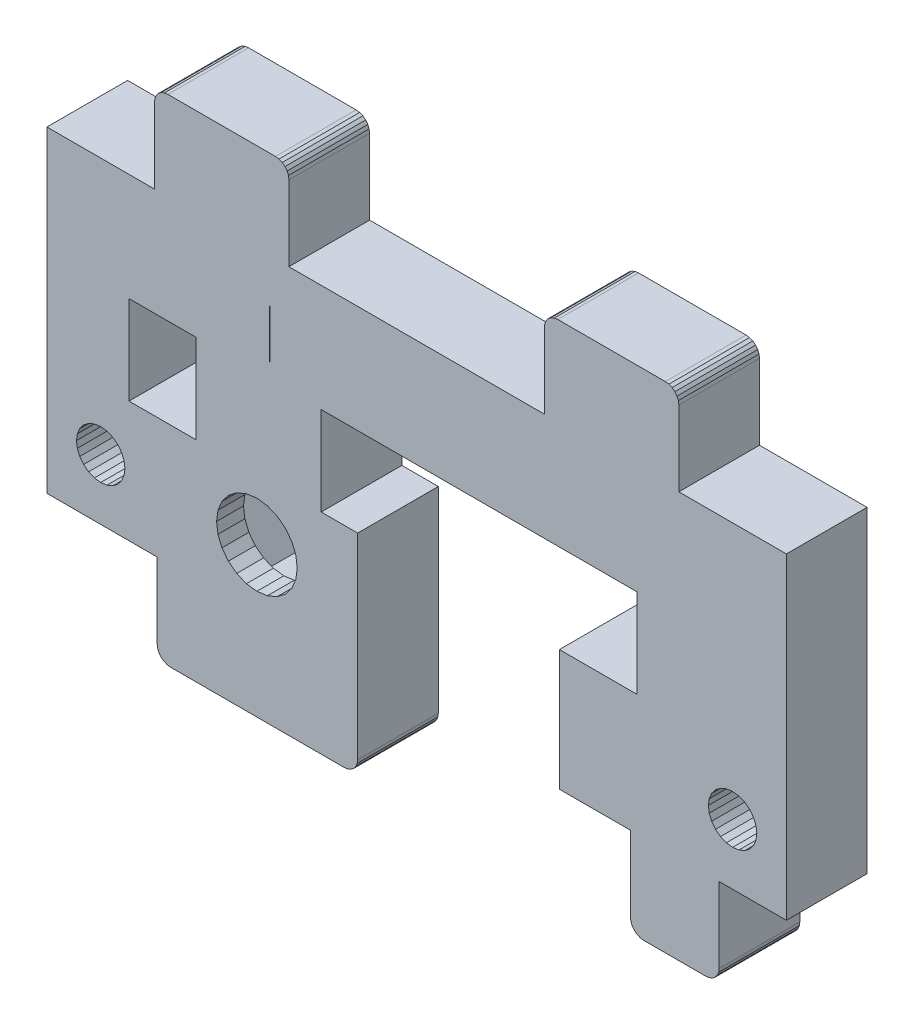
from build123d import *

# Parameters (mm, degrees)
BOSS_EXTRUDE1_DEPTH = 6
BOSS_EXTRUDE2_DEPTH = 2


with BuildPart() as part:
    # Sketch1 → Boss-Extrude1 (new body)
    with BuildSketch(Plane.XY):
        Polygon((-427.733097117, -199.387732928), (-427.525990336, -199.228814306), (-427.367071713, -199.021707525), (-427.267171291, -198.78052657), (-427.233097117, -198.521707525), (-427.233097117, -183.921707525), (-429.945372541, -183.921707525), (-429.945372541, -177.321707525), (-406.445372541, -177.321707525), (-406.445372541, -183.921707525), (-412.227908952, -183.921707525), (-412.227908952, -192.921707525), (-406.945372541, -192.921707525), (-406.945372541, -198.521707525), (-406.911298367, -198.78052657), (-406.811397945, -199.021707525), (-406.652479322, -199.228814306), (-406.445372541, -199.387732928), (-406.204191586, -199.487633351), (-405.945372541, -199.521707525), (-401.345372541, -199.521707525), (-401.086553496, -199.487633351), (-400.845372541, -199.387732928), (-400.63826576, -199.228814306), (-400.479347137, -199.021707525), (-400.379446715, -198.78052657), (-400.345372541, -198.521707525), (-400.345372541, -192.921707525), (-395.345372541, -192.921707525), (-395.345372541, -169.321707525), (-403.345372541, -169.321707525), (-403.345372541, -163.721707525), (-403.379446715, -163.46288848), (-403.479347137, -163.221707525), (-403.63826576, -163.014600744), (-403.845372541, -162.855682121), (-404.086553496, -162.755781698), (-404.345372541, -162.721707525), (-412.345372541, -162.721707525), (-412.604191586, -162.755781698), (-412.845372541, -162.855682121), (-413.052479322, -163.014600744), (-413.211397945, -163.221707525), (-413.311298367, -163.46288848), (-413.345372541, -163.721707525), (-413.345372541, -169.321707525), (-432.345372541, -169.321707525), (-432.345372541, -163.721707525), (-432.379446715, -163.46288848), (-432.479347137, -163.221707525), (-432.63826576, -163.014600744), (-432.845372541, -162.855682121), (-433.086553496, -162.755781698), (-433.345372541, -162.721707525), (-441.345372541, -162.721707525), (-441.604191586, -162.755781698), (-441.845372541, -162.855682121), (-442.052479322, -163.014600744), (-442.211397945, -163.221707525), (-442.311298367, -163.46288848), (-442.345372541, -163.721707525), (-442.345372541, -169.321707525), (-450.345372541, -169.321707525), (-450.345372541, -192.921707525), (-442.145372541, -192.921707525), (-442.145372541, -198.521707525), (-442.111298367, -198.78052657), (-442.011397945, -199.021707525), (-441.852479322, -199.228814306), (-441.645372541, -199.387732928), (-441.404191586, -199.487633351), (-441.145372541, -199.521707525), (-428.233097117, -199.521707525), (-427.974278072, -199.487633351), align=None)
        Polygon((-447.618164747, -187.148915319), (-447.245372541, -186.862861798), (-446.811246822, -186.683041037), (-446.345372541, -186.621707525), (-445.87949826, -186.683041037), (-445.445372541, -186.862861798), (-445.072580335, -187.148915319), (-444.786526814, -187.521707525), (-444.606706054, -187.955833244), (-444.545372541, -188.421707525), (-444.606706054, -188.887581806), (-444.786526814, -189.321707525), (-445.072580335, -189.694499731), (-445.445372541, -189.980553252), (-445.87949826, -190.160374012), (-446.345372541, -190.221707525), (-446.811246822, -190.160374012), (-447.245372541, -189.980553252), (-447.618164747, -189.694499731), (-447.904218268, -189.321707525), (-448.084039028, -188.887581806), (-448.145372541, -188.421707525), (-448.084039028, -187.955833244), (-447.904218268, -187.521707525), align=None, mode=Mode.SUBTRACT)
        Polygon((-432.11197341, -192.934124647), (-437.308125833, -192.934124647), (-439.906202044, -188.434124647), (-437.308125833, -183.934124647), (-432.11197341, -183.934124647), (-429.513897199, -188.434124647), align=None, mode=Mode.SUBTRACT)
        Polygon((-400.904218268, -187.521707525), (-400.618164747, -187.148915319), (-400.245372541, -186.862861798), (-399.811246822, -186.683041037), (-399.345372541, -186.621707525), (-398.87949826, -186.683041037), (-398.445372541, -186.862861798), (-398.072580335, -187.148915319), (-397.786526814, -187.521707525), (-397.606706054, -187.955833244), (-397.545372541, -188.421707525), (-397.606706054, -188.887581806), (-397.786526814, -189.321707525), (-398.072580335, -189.694499731), (-398.445372541, -189.980553252), (-398.87949826, -190.160374012), (-399.345372541, -190.221707525), (-399.811246822, -190.160374012), (-400.245372541, -189.980553252), (-400.618164747, -189.694499731), (-400.904218268, -189.321707525), (-401.084039028, -188.887581806), (-401.145372541, -188.421707525), (-401.084039028, -187.955833244), align=None, mode=Mode.SUBTRACT)
        Polygon((-439.245372541, -177.321707525), (-439.240180663, -183.921707525), (-444.240179116, -183.925640764), (-444.245370992, -177.325642806), align=None, mode=Mode.SUBTRACT)
        Polygon((-433.771349426, -172.366944559), (-433.771349426, -176.175776495), (-433.791446368, -176.271985766), align=None, mode=Mode.SUBTRACT)
    extrude(amount=-BOSS_EXTRUDE1_DEPTH)

    # Sketch1_3 → Boss-Extrude2 (add)
    with BuildSketch(Plane.XY):
        Polygon((-439.906202044, -188.434124647), (-437.308125833, -192.934124647), (-432.11197341, -192.934124647), (-429.513897199, -188.434124647), (-432.11197341, -183.934124647), (-437.308125833, -183.934124647), align=None)
        Polygon((-432.129832741, -189.921707525), (-432.606588608, -190.543027868), (-433.227908952, -191.019783736), (-433.951451817, -191.319485004), (-434.727908952, -191.421707525), (-435.504366087, -191.319485004), (-436.227908952, -191.019783736), (-436.849229296, -190.543027868), (-437.325985163, -189.921707525), (-437.625686431, -189.19816466), (-437.727908952, -188.421707525), (-437.625686431, -187.645250389), (-437.325985163, -186.921707525), (-436.849229296, -186.300387181), (-436.227908952, -185.823631313), (-435.504366087, -185.523930046), (-434.727908952, -185.421707525), (-433.951451817, -185.523930046), (-433.227908952, -185.823631313), (-432.606588608, -186.300387181), (-432.129832741, -186.921707525), (-431.830131473, -187.645250389), (-431.727908952, -188.421707525), (-431.830131473, -189.19816466), align=None, mode=Mode.SUBTRACT)
    extrude(amount=-BOSS_EXTRUDE2_DEPTH)


solid = part.part
